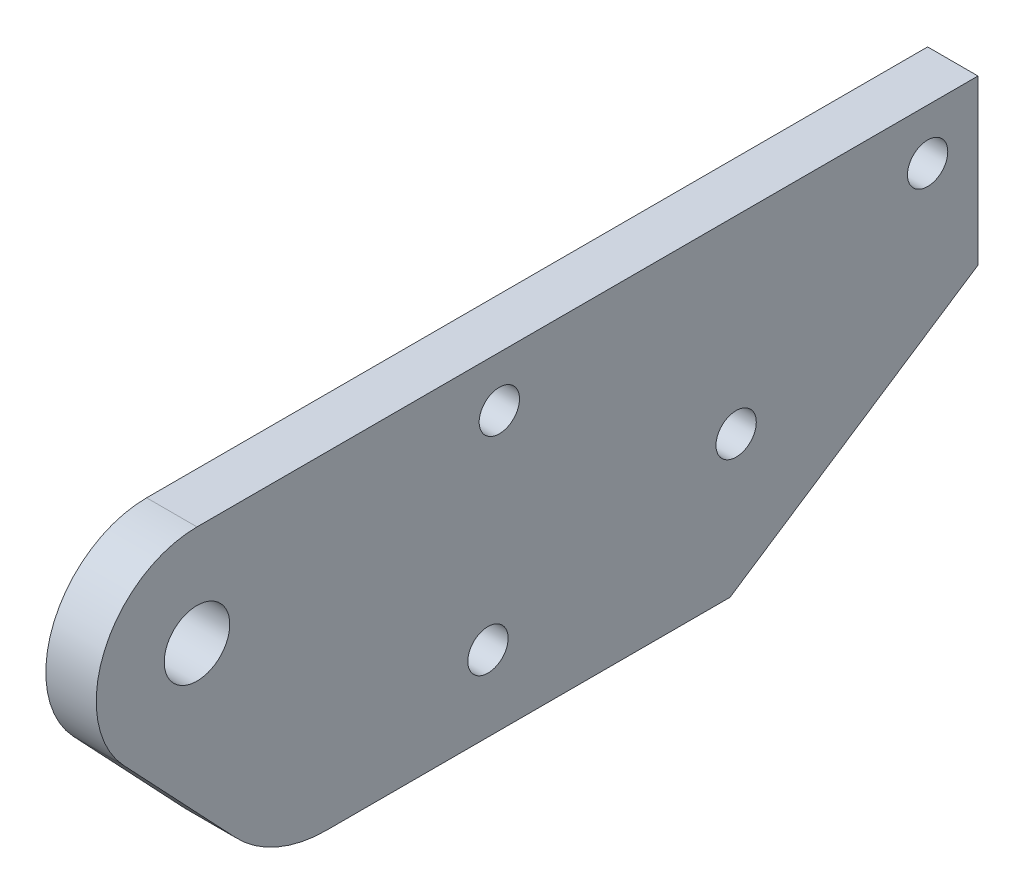
from build123d import *

# Parameters (mm, degrees)
SKETCH_1_R      = 1.6
SKETCH_1_R_2    = 2.6
EXTRUDE_1_DEPTH = 4


with BuildPart() as part:
    # 草图1 → 凸台-拉伸1 (new body)
    with BuildSketch(Plane(origin=(0, 0, 0), x_dir=(0, 0, -1), z_dir=(1, 0, 0))):
        with BuildLine():
            Line((8.104883027, 1.878840053), (27.795402052, 14.878840053))
            Line((27.795402052, 14.878840053), (27.795402052, 27.878840053))
            Line((27.795402052, 27.878840053), (-34.204597948, 27.878840053))
            ThreePointArc((-34.204597948, 27.878840053), (-41.551421317, 23.044939607), (-40.019791495, 14.384886649))
            Line((-40.019791495, 14.384886649), (-31.164108907, 5.011398298))
            ThreePointArc((-31.164108907, 5.011398298), (-27.852741415, 2.695310842), (-23.895116973, 1.878840053))
            Line((-23.895116973, 1.878840053), (8.104883027, 1.878840053))
        make_face()
        with Locations((23.795402052, 23.878840053)):
            Circle(SKETCH_1_R, mode=Mode.SUBTRACT)
        with Locations((-10.204597948, 23.878840053)):
            Circle(SKETCH_1_R, mode=Mode.SUBTRACT)
        with Locations((8.595402052, 12.878840053)):
            Circle(SKETCH_1_R, mode=Mode.SUBTRACT)
        with Locations((-11.104597948, 7.878840053)):
            Circle(SKETCH_1_R, mode=Mode.SUBTRACT)
        with Locations((-34.204597948, 19.878840053)):
            Circle(SKETCH_1_R_2, mode=Mode.SUBTRACT)
    extrude(amount=EXTRUDE_1_DEPTH)


solid = part.part
